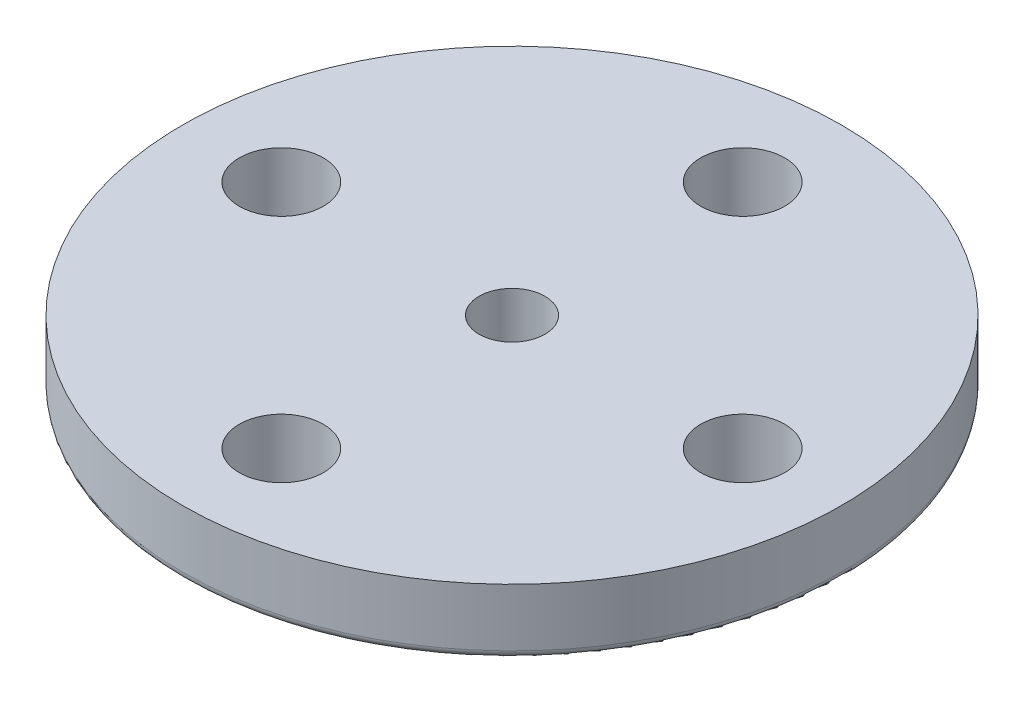
from build123d import *

# Parameters (mm, degrees)
SKETCH1_R           = 10
BOSS_EXTRUDE1_DEPTH = 2
SKETCH2_R           = 4.5
BOSS_EXTRUDE2_DEPTH = 2.5
SKETCH3_R           = 1.275
CUT_EXTRUDE1_DEPTH  = 3
FILLET1_R           = 0.25
SKETCH6_R           = 1
CUT_EXTRUDE2_DEPTH  = 5.5
SKETCH7_R           = 2.9
CUT_EXTRUDE3_DEPTH  = 2.5
BOSS_EXTRUDE4_DEPTH = 2.5
CIRPATTERN1_COUNT   = 26


with BuildPart() as part:
    # Sketch1 → Boss-Extrude1 (new body)
    with BuildSketch(Plane(origin=(0, 0, 0), x_dir=(1, 0, 0), z_dir=(0, 1, 0))):
        Circle(SKETCH1_R)
    extrude(amount=BOSS_EXTRUDE1_DEPTH)

    # Sketch2 → Boss-Extrude2 (add)
    with BuildSketch(Plane(origin=(0, 0, 0), x_dir=(1, 0, 0), z_dir=(0, 1, 0))):
        Circle(SKETCH2_R)
    extrude(amount=-BOSS_EXTRUDE2_DEPTH)

    # Sketch3 → Cut-Extrude1 (cut, through all)
    with BuildSketch(Plane(origin=(0, 0, 0), x_dir=(1, 0, 0), z_dir=(0, 1, 0))):
        with Locations((0, 7)):
            Circle(SKETCH3_R)
        with Locations((-7, 0)):
            Circle(SKETCH3_R)
        with Locations((0, -7)):
            Circle(SKETCH3_R)
        with Locations((7, 0)):
            Circle(SKETCH3_R)
    extrude(amount=CUT_EXTRUDE1_DEPTH, mode=Mode.SUBTRACT)

    # Fillet1
    fillet1_edges = [part.edges().sort_by_distance(p)[0] for p in [
        (-10, 0, 0),
    ]]
    fillet(fillet1_edges, radius=FILLET1_R)

    # Sketch6 → Cut-Extrude2 (cut, through all)
    with BuildSketch(Plane(origin=(0, 2, 0), x_dir=(1, 0, 0), z_dir=(0, 1, 0))):
        Circle(SKETCH6_R)
    extrude(amount=-CUT_EXTRUDE2_DEPTH, mode=Mode.SUBTRACT)

    # Sketch7 → Cut-Extrude3 (cut)
    with BuildSketch(Plane.XZ.offset(2.5)):
        Circle(SKETCH7_R)
    extrude(amount=-CUT_EXTRUDE3_DEPTH, mode=Mode.SUBTRACT)

    # Sketch8 → Boss-Extrude4 (add)
    with BuildSketch(Plane.XZ.offset(2.5)):
        with BuildLine():
            Line((-2.35244742, -1.046531787), (-2.745588284, -0.933672842))
            ThreePointArc((-2.745588284, -0.933672842), (-2.649635472, -1.178741646), (-2.531859978, -1.414102207))
            Line((-2.531859978, -1.414102207), (-2.35244742, -1.046531787))
        make_face()
    boss_extrude4 = extrude(amount=-BOSS_EXTRUDE4_DEPTH)

    # CirPattern1: Boss-Extrude4 ×26 about axis
    cirpattern1_axis = Axis((0, 0, 0), (0, 1, 0))
    for i in range(1, CIRPATTERN1_COUNT):
        add(boss_extrude4.rotate(cirpattern1_axis, i * 360 / CIRPATTERN1_COUNT))


solid = part.part
